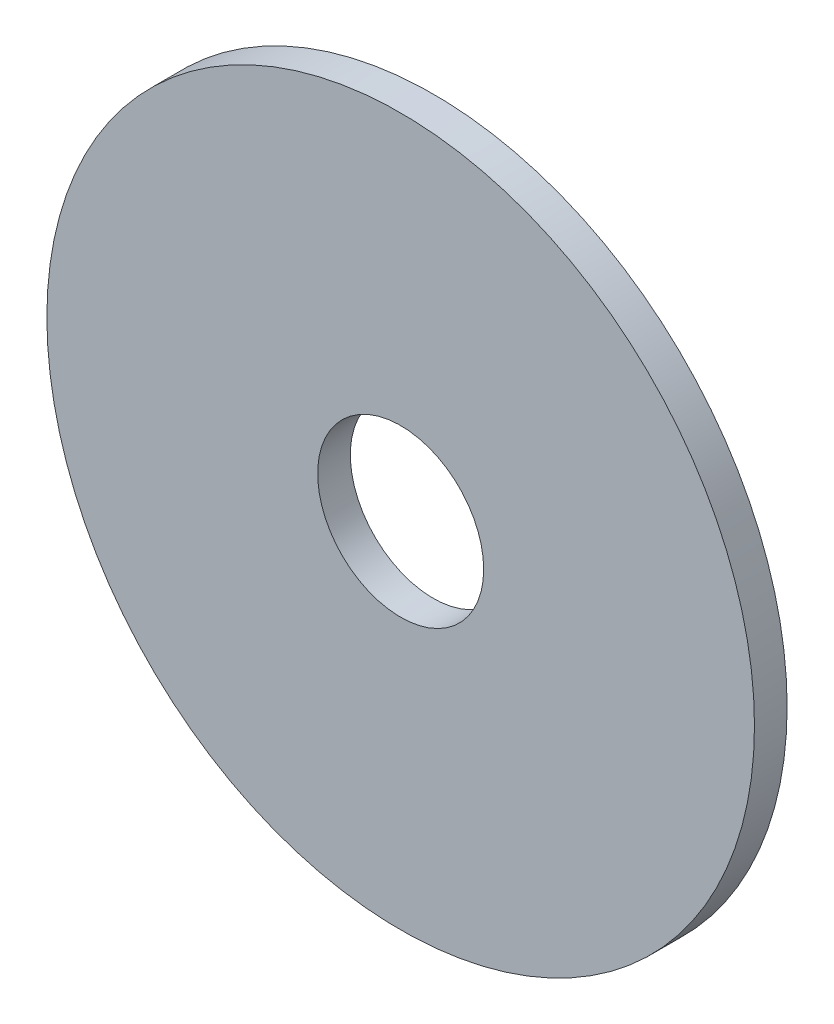
from build123d import *

# Parameters (mm, degrees)
SKETCH1_R           = 65
BOSS_EXTRUDE1_DEPTH = 6
SKETCH2_R           = 15.25
CUT_EXTRUDE1_DEPTH  = 6


with BuildPart() as part:
    # Sketch1 → Boss-Extrude1 (new body)
    with BuildSketch(Plane.XY):
        Circle(SKETCH1_R)
    extrude(amount=BOSS_EXTRUDE1_DEPTH)

    # Sketch2 → Cut-Extrude1 (cut)
    with BuildSketch(Plane.XY.offset(6)):
        Circle(SKETCH2_R)
    extrude(amount=-CUT_EXTRUDE1_DEPTH, mode=Mode.SUBTRACT)


solid = part.part
